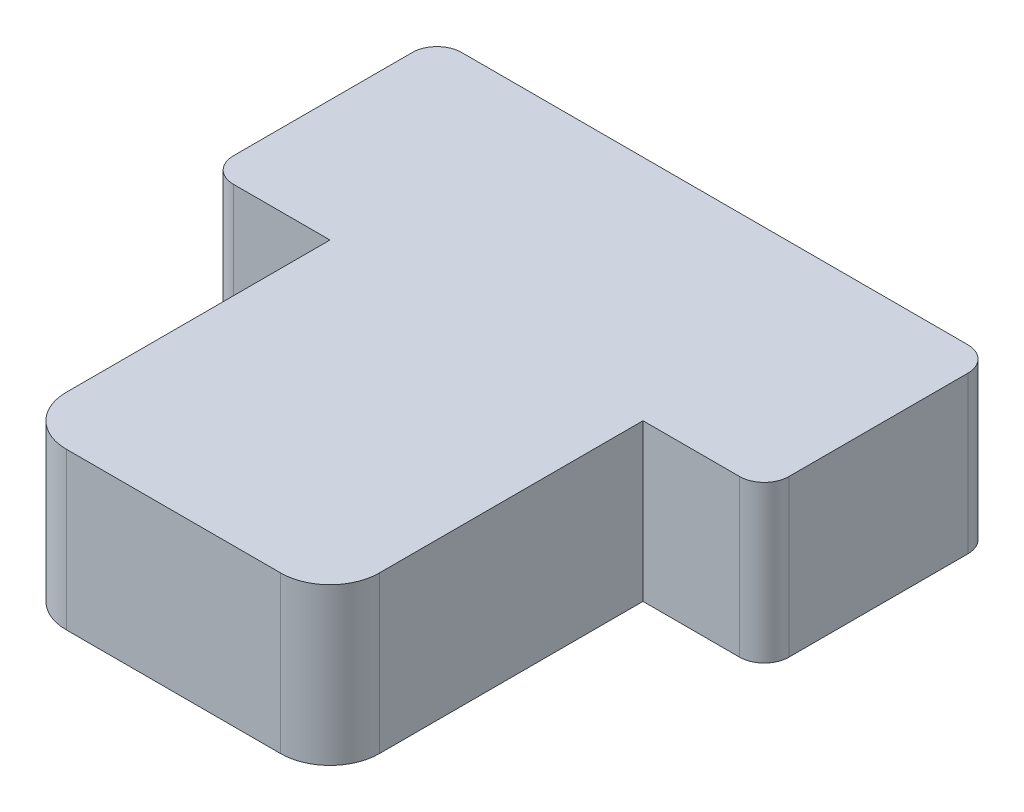
from build123d import *

# Parameters (mm, degrees)
MOTORSUPPORT_EXTRUDE_DEPTH  = 3.175
MOTORSUPPORT_BOTTOMFILLET_R = 1
MOTORSUPPORT_TOPFILLET_R    = 0.5


with BuildPart() as part:
    # Sketch1 → MotorSupport_Extrude (new body)
    with BuildSketch(Plane(origin=(0, 0, 0), x_dir=(1, 0, 0), z_dir=(0, 1, 0))):
        Polygon((0, 0), (6.35, 0), (6.35, 6.35), (8.81, 6.35), (8.81, 10.9807274), (-2.46, 10.9807274), (-2.46, 6.35), (0, 6.35), align=None)
    extrude(amount=MOTORSUPPORT_EXTRUDE_DEPTH)

    # MotorSupport_BottomFillet
    motorsupport_bottomfillet_edges = [part.edges().sort_by_distance(p)[0] for p in [
        (6.35, 1.5875, 0),
        (0, 1.5875, 0),
    ]]
    fillet(motorsupport_bottomfillet_edges, radius=MOTORSUPPORT_BOTTOMFILLET_R)

    # MotorSupport_TopFillet
    motorsupport_topfillet_edges = [part.edges().sort_by_distance(p)[0] for p in [
        (-2.46, 1.5875, -6.35),
        (-2.46, 1.5875, -10.9807274),
        (8.81, 1.5875, -10.9807274),
        (8.81, 1.5875, -6.35),
    ]]
    fillet(motorsupport_topfillet_edges, radius=MOTORSUPPORT_TOPFILLET_R)


solid = part.part
